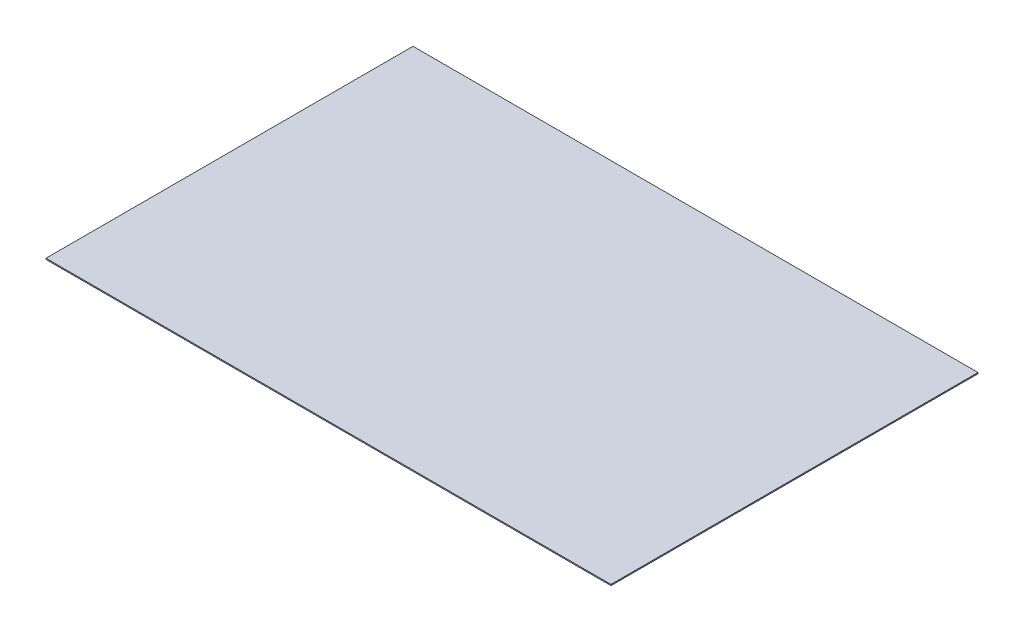
from build123d import *

# Parameters (mm, degrees)
SKETCH1_W           = 809.752
SKETCH1_H           = 526.034
BOSS_EXTRUDE1_DEPTH = 1.5875


with BuildPart() as part:
    # Sketch1 → Boss-Extrude1 (new body)
    with BuildSketch(Plane(origin=(0, 0, 0), x_dir=(1, 0, 0), z_dir=(0, 1, 0))):
        with Locations((404.876, 263.017)):
            Rectangle(SKETCH1_W, SKETCH1_H)
    extrude(amount=BOSS_EXTRUDE1_DEPTH)


solid = part.part
